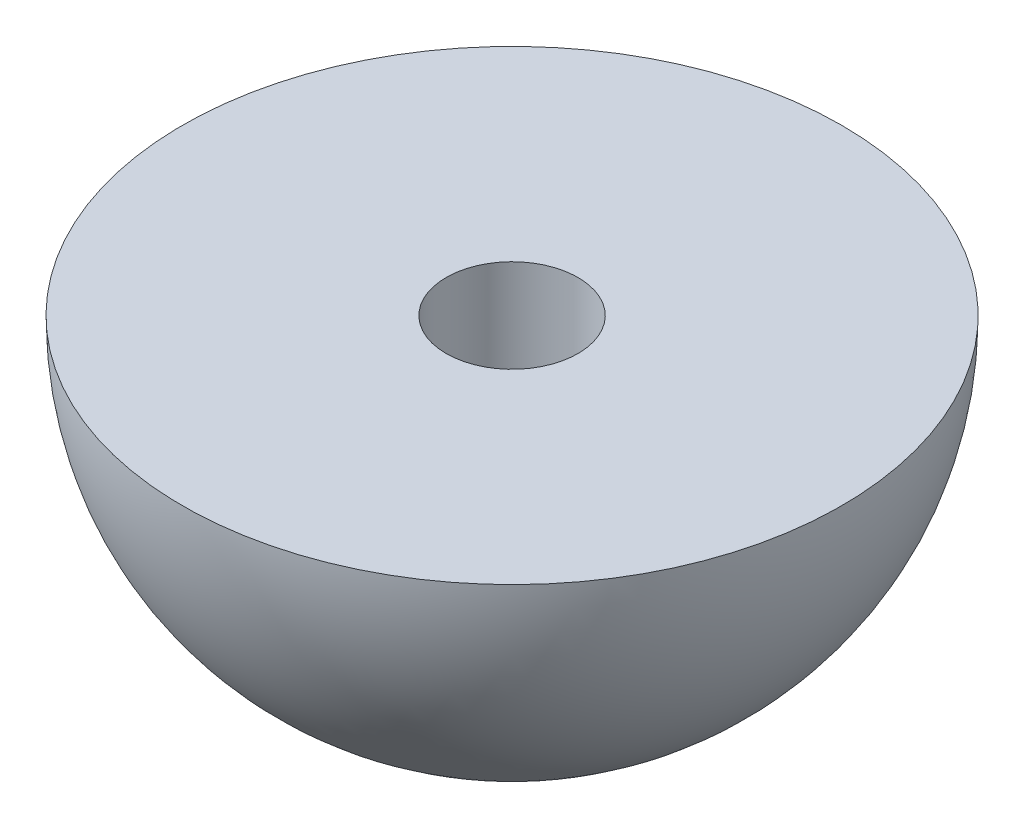
from build123d import *

# Parameters (mm, degrees)
SKETCH_2_R          = 1.6
CUT_EXTRUDE_1_DEPTH = 9


with BuildPart() as part:
    # ｽｹｯﾁ1 → 回転1 (revolve)
    with BuildSketch(Plane.XY):
        with BuildLine():
            Line((0, -8), (0, 0))
            Line((0, 0), (8, 0))
            ThreePointArc((8, 0), (5.656854249, -5.656854249), (0, -8))
        make_face()
    revolve(axis=Axis((0, -8, 0), (0, 1, 0)))

    # ｽｹｯﾁ2 → ｶｯﾄ - 押し出し1 (cut, through all)
    with BuildSketch(Plane(origin=(0, 0, 0), x_dir=(1, 0, 0), z_dir=(0, 1, 0))):
        Circle(SKETCH_2_R)
    extrude(amount=-CUT_EXTRUDE_1_DEPTH, mode=Mode.SUBTRACT)


solid = part.part
